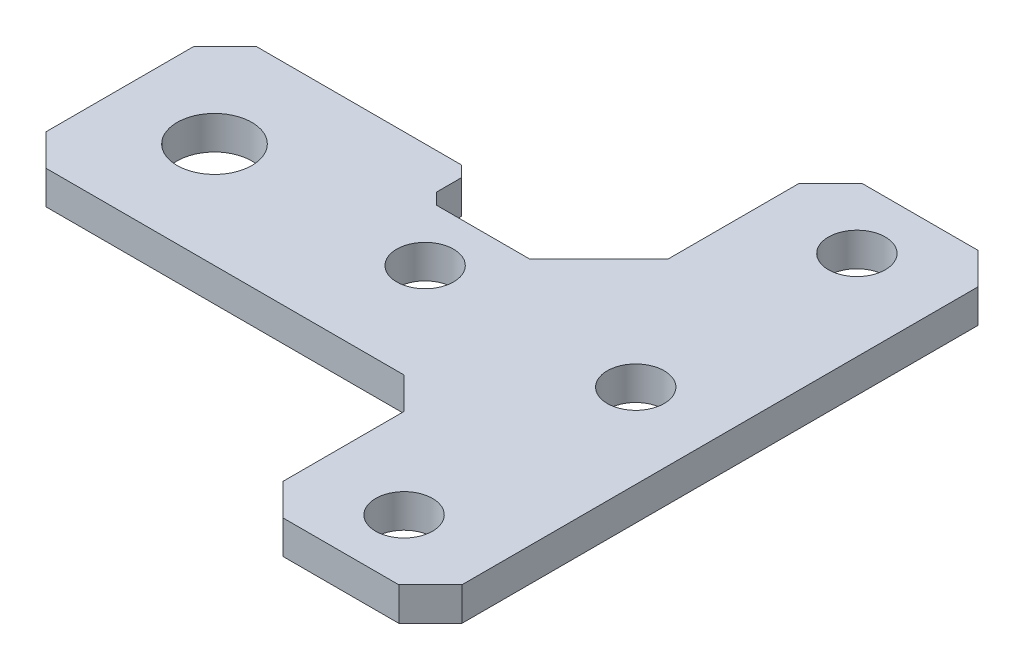
from build123d import *

# Parameters (mm, degrees)
SKETCH1_R           = 2.7
SKETCH1_R_2         = 3.55
BOSS_EXTRUDE1_DEPTH = 3.175
CHAMFER1_SIZE       = 3
CUT_EXTRUDE2_REACH  = 5.175
CUT_EXTRUDE3_START  = -3.175
SKETCH8_W           = 11
SKETCH8_H           = 1.8
CUT_EXTRUDE3_DEPTH  = 3.175
SKETCH9_W           = 8.878679656
SKETCH9_H           = 1.6
BOSS_EXTRUDE2_DEPTH = 3.175
BOSS_EXTRUDE3_DEPTH = 3.175
CUT_EXTRUDE4_REACH  = 5.175
CHAMFER3_SIZE       = 1.060660172
CHAMFER4_SIZE       = 3


with BuildPart() as part:
    # Sketch1 → Boss-Extrude1 (new body)
    with BuildSketch(Plane(origin=(0, 0, 0), x_dir=(1, 0, 0), z_dir=(0, 1, 0))):
        Polygon((0, 0), (40, 0), (40, -17.5), (57, -17.5), (57, 37.5), (40, 37.5), (40, 20), (0, 20), align=None)
        with Locations((29, 10)):
            Circle(SKETCH1_R, mode=Mode.SUBTRACT)
        with Locations((9, 10)):
            Circle(SKETCH1_R_2, mode=Mode.SUBTRACT)
        with Locations((48.5, 31.5)):
            Circle(SKETCH1_R, mode=Mode.SUBTRACT)
        with Locations((48.5, -11.5)):
            Circle(SKETCH1_R, mode=Mode.SUBTRACT)
        with Locations((49, 10)):
            Circle(SKETCH1_R, mode=Mode.SUBTRACT)
    extrude(amount=BOSS_EXTRUDE1_DEPTH)

    # Chamfer1
    chamfer1_edges = [part.edges().sort_by_distance(p)[0] for p in [
        (0, 1.5875, -20),
        (40, 1.5875, -37.5),
        (57, 1.5875, -37.5),
        (57, 1.5875, 17.5),
        (40, 1.5875, 17.5),
        (0, 1.5875, 0),
    ]]
    chamfer(chamfer1_edges, length=CHAMFER1_SIZE)

    # Sketch6 → Cut-Extrude2 (cut, up to next)
    with BuildSketch(Plane(origin=(0, 3.175, 0), x_dir=(1, 0, 0), z_dir=(0, 1, 0)), mode=Mode.PRIVATE) as cut_extrude2_sk1:
        Polygon((23.5, 16.560660172), (26.160660172, 13.9), (31.839339828, 13.9), (34.5, 16.560660172), (34.5, 18.2), (32.125, 18.2), (32.125, 18.545), (33.58, 20), (24.42, 20), (25.875, 18.545), (25.875, 18.2), (23.5, 18.2), align=None)
    cut_extrude2_tool1 = extrude(cut_extrude2_sk1.sketch, amount=-CUT_EXTRUDE2_REACH, mode=Mode.PRIVATE) & part.part
    add(cut_extrude2_tool1.solids().sort_by_distance((29, 3.175, -16.994051))[0], mode=Mode.SUBTRACT)

    # Sketch8 → Cut-Extrude3 (cut)
    with BuildSketch(Plane.XZ.offset(CUT_EXTRUDE3_START)):
        with Locations((29, -19.1)):
            Rectangle(SKETCH8_W, SKETCH8_H)
    extrude(amount=CUT_EXTRUDE3_DEPTH, mode=Mode.SUBTRACT)

    # Sketch9 → Boss-Extrude2 (add)
    with BuildSketch(Plane(origin=(0, 0, 0), x_dir=(-1, 0, 0), z_dir=(0, -1, 0))):
        with Locations((-29, 14.7)):
            Rectangle(SKETCH9_W, SKETCH9_H)
    extrude(amount=-BOSS_EXTRUDE2_DEPTH)

    # Sketch10 → Boss-Extrude3 (add)
    with BuildSketch(Plane.XZ):
        Polygon((40, -22.060660172), (40, -20), (37.939339828, -20), align=None)
    extrude(amount=-BOSS_EXTRUDE3_DEPTH)

    # Sketch11 → Cut-Extrude4 (cut, up to next)
    with BuildSketch(Plane.XZ, mode=Mode.PRIVATE) as cut_extrude4_sk1:
        Polygon((34.5, -16.560660172), (37.939339828, -20), (34.5, -20), align=None)
    cut_extrude4_tool1 = extrude(cut_extrude4_sk1.sketch, amount=-CUT_EXTRUDE4_REACH, mode=Mode.PRIVATE) & part.part
    add(cut_extrude4_tool1.solids().sort_by_distance((35.646447, 0, -18.853553))[0], mode=Mode.SUBTRACT)

    # Chamfer3
    chamfer3_edges = [part.edges().sort_by_distance(p)[0] for p in [
        (23.5, 1.5875, -20),
    ]]
    chamfer(chamfer3_edges, length=CHAMFER3_SIZE)

    # Chamfer4
    chamfer4_edges = [part.edges().sort_by_distance(p)[0] for p in [
        (40, 1.5875, 0),
    ]]
    chamfer(chamfer4_edges, length=CHAMFER4_SIZE)


solid = part.part
